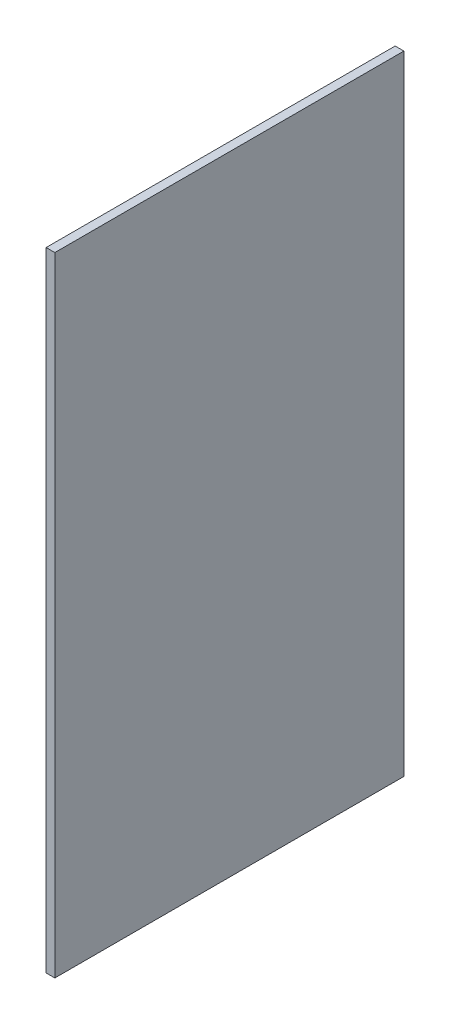
from build123d import *

# Parameters (mm, degrees)
SKETCH1_W           = 720
SKETCH1_H           = 400
BOSS_EXTRUDE1_DEPTH = 10


with BuildPart() as part:
    # Sketch1 → Boss-Extrude1 (new body)
    with BuildSketch(Plane(origin=(0, 0, 0), x_dir=(0, -1, 0), z_dir=(1, 0, 0))):
        Rectangle(SKETCH1_W, SKETCH1_H)
    extrude(amount=BOSS_EXTRUDE1_DEPTH)


solid = part.part
